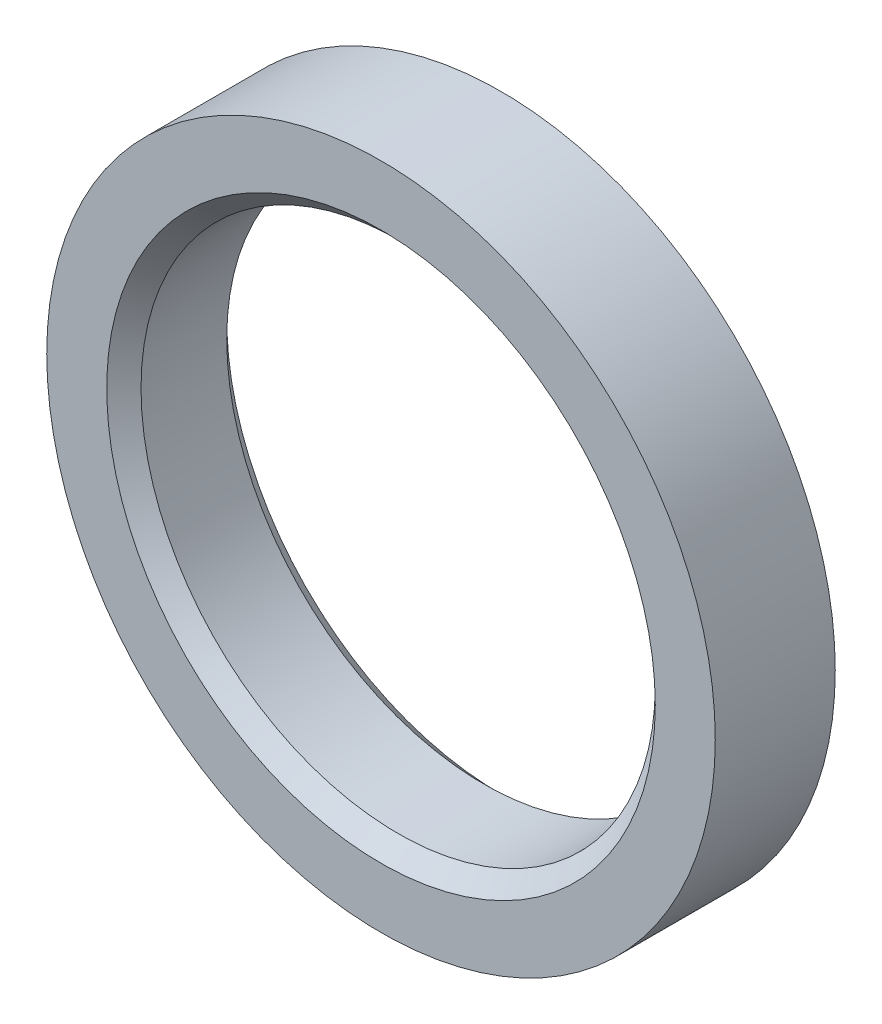
from build123d import *

# Parameters (mm, degrees)
SZKIC1_R                   = 19.5
SZKIC1_R_2                 = 15
WYCI_GNI_CIE_PROSTE1_DEPTH = 7
FAZA2_SIZE                 = 1


with BuildPart() as part:
    # Szkic1 → Wyciągnięcie proste1 (new body)
    with BuildSketch(Plane.XY):
        Circle(SZKIC1_R)
        Circle(SZKIC1_R_2, mode=Mode.SUBTRACT)
    extrude(amount=WYCI_GNI_CIE_PROSTE1_DEPTH)

    # Faza2
    faza2_edges = [part.edges().sort_by_distance(p)[0] for p in [
        (-15, 0, 0),
        (-15, 0, 7),
    ]]
    chamfer(faza2_edges, length=FAZA2_SIZE)


solid = part.part
